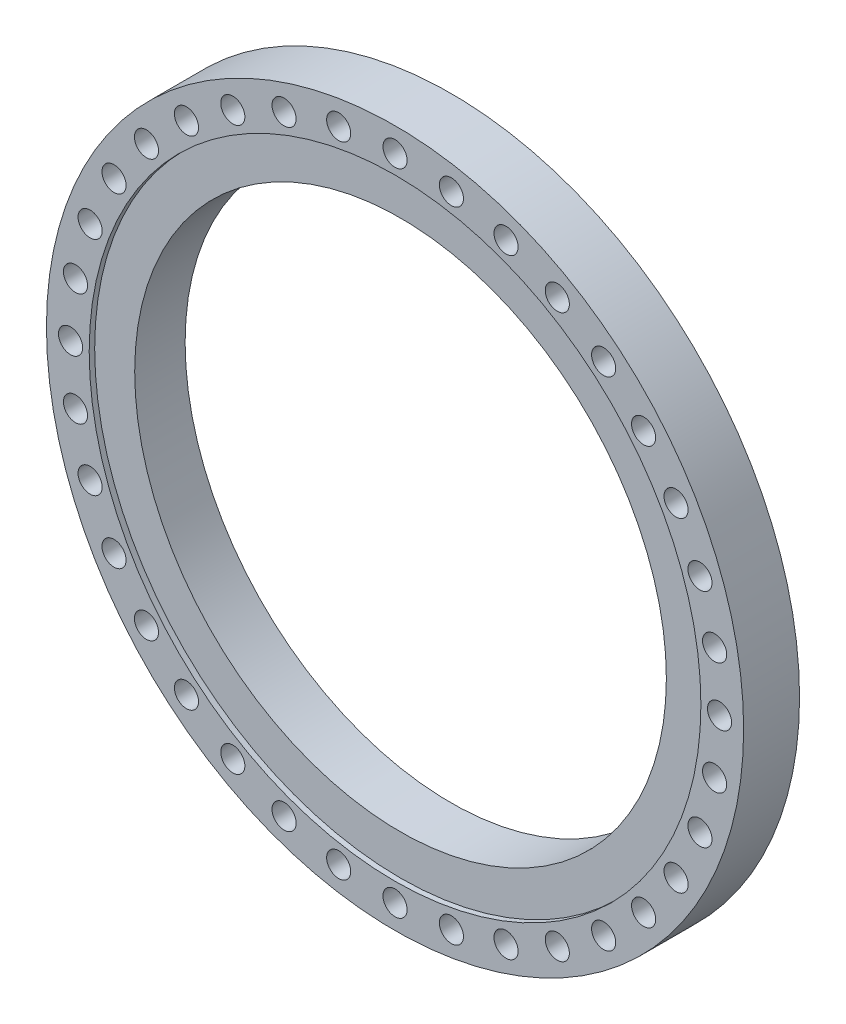
from build123d import *

# Parameters (mm, degrees)
SKETCH1_R           = 318
SKETCH1_R_2         = 242.5
BOSS_EXTRUDE1_DEPTH = 25.5
SKETCH2_R           = 279
CUT_EXTRUDE1_DEPTH  = 5
SKETCH3_R           = 11
CUT_EXTRUDE2_DEPTH  = 27.5


with BuildPart() as part:
    # Sketch1 → Boss-Extrude1 (new body, symmetric)
    with BuildSketch(Plane.XY):
        Circle(SKETCH1_R)
        Circle(SKETCH1_R_2, mode=Mode.SUBTRACT)
    extrude(amount=BOSS_EXTRUDE1_DEPTH, both=True)

    # Sketch2 → Cut-Extrude1 (cut)
    with BuildSketch(Plane.XY.offset(25.5)):
        Circle(SKETCH2_R)
    extrude(amount=-CUT_EXTRUDE1_DEPTH, mode=Mode.SUBTRACT)

    # Sketch3 → Cut-Extrude2 (cut, symmetric)
    with BuildSketch(Plane.XY):
        with Locations((0, 296)):
            Circle(SKETCH3_R)
        with Locations((51.399860589, 291.503094892)):
            Circle(SKETCH3_R)
        with Locations((101.237962424, 278.149015753)):
            Circle(SKETCH3_R)
        with Locations((148, 256.34351952)):
            Circle(SKETCH3_R)
        with Locations((190.265132467, 226.749155163)):
            Circle(SKETCH3_R)
        with Locations((226.749155163, 190.265132467)):
            Circle(SKETCH3_R)
        with Locations((256.34351952, 148)):
            Circle(SKETCH3_R)
        with Locations((278.149015753, 101.237962424)):
            Circle(SKETCH3_R)
        with Locations((291.503094892, 51.399860589)):
            Circle(SKETCH3_R)
        with Locations((296, 0)):
            Circle(SKETCH3_R)
        with Locations((291.503094892, -51.399860589)):
            Circle(SKETCH3_R)
        with Locations((278.149015753, -101.237962424)):
            Circle(SKETCH3_R)
        with Locations((256.34351952, -148)):
            Circle(SKETCH3_R)
        with Locations((226.749155163, -190.265132467)):
            Circle(SKETCH3_R)
        with Locations((190.265132467, -226.749155163)):
            Circle(SKETCH3_R)
        with Locations((148, -256.34351952)):
            Circle(SKETCH3_R)
        with Locations((101.237962424, -278.149015753)):
            Circle(SKETCH3_R)
        with Locations((51.399860589, -291.503094892)):
            Circle(SKETCH3_R)
        with Locations((0, -296)):
            Circle(SKETCH3_R)
        with Locations((-51.399860589, -291.503094892)):
            Circle(SKETCH3_R)
        with Locations((-101.237962424, -278.149015753)):
            Circle(SKETCH3_R)
        with Locations((-148, -256.34351952)):
            Circle(SKETCH3_R)
        with Locations((-190.265132467, -226.749155163)):
            Circle(SKETCH3_R)
        with Locations((-226.749155163, -190.265132467)):
            Circle(SKETCH3_R)
        with Locations((-256.34351952, -148)):
            Circle(SKETCH3_R)
        with Locations((-278.149015753, -101.237962424)):
            Circle(SKETCH3_R)
        with Locations((-291.503094892, -51.399860589)):
            Circle(SKETCH3_R)
        with Locations((-296, 0)):
            Circle(SKETCH3_R)
        with Locations((-291.503094892, 51.399860589)):
            Circle(SKETCH3_R)
        with Locations((-278.149015753, 101.237962424)):
            Circle(SKETCH3_R)
        with Locations((-256.34351952, 148)):
            Circle(SKETCH3_R)
        with Locations((-226.749155163, 190.265132467)):
            Circle(SKETCH3_R)
        with Locations((-190.265132467, 226.749155163)):
            Circle(SKETCH3_R)
        with Locations((-148, 256.34351952)):
            Circle(SKETCH3_R)
        with Locations((-101.237962424, 278.149015753)):
            Circle(SKETCH3_R)
        with Locations((-51.399860589, 291.503094892)):
            Circle(SKETCH3_R)
    extrude(amount=CUT_EXTRUDE2_DEPTH, both=True, mode=Mode.SUBTRACT)


solid = part.part
